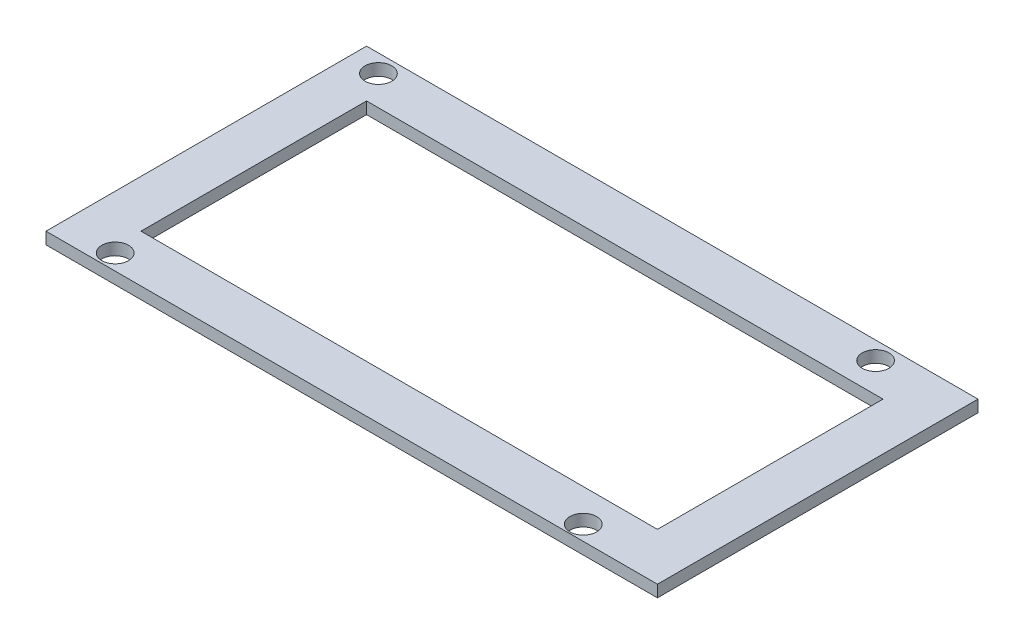
from build123d import *

# Parameters (mm, degrees)
SKETCH1_W           = 103
SKETCH1_H           = 54
SKETCH1_R           = 2.25
SKETCH1_W_2         = 87
SKETCH1_H_2         = 38
BOSS_EXTRUDE1_DEPTH = 2


with BuildPart() as part:
    # Sketch1 → Boss-Extrude1 (new body)
    with BuildSketch(Plane(origin=(0, 0, 0), x_dir=(1, 0, 0), z_dir=(0, 1, 0))):
        with Locations((51.5, 27)):
            Rectangle(SKETCH1_W, SKETCH1_H)
        with Locations((88.75, 51)):
            Circle(SKETCH1_R, mode=Mode.SUBTRACT)
        with Locations((88, 2.5)):
            Circle(SKETCH1_R, mode=Mode.SUBTRACT)
        with Locations((5, 51)):
            Circle(SKETCH1_R, mode=Mode.SUBTRACT)
        with Locations((9, 2.65)):
            Circle(SKETCH1_R, mode=Mode.SUBTRACT)
        with Locations((51.5, 27)):
            Rectangle(SKETCH1_W_2, SKETCH1_H_2, mode=Mode.SUBTRACT)
    extrude(amount=BOSS_EXTRUDE1_DEPTH)


solid = part.part
